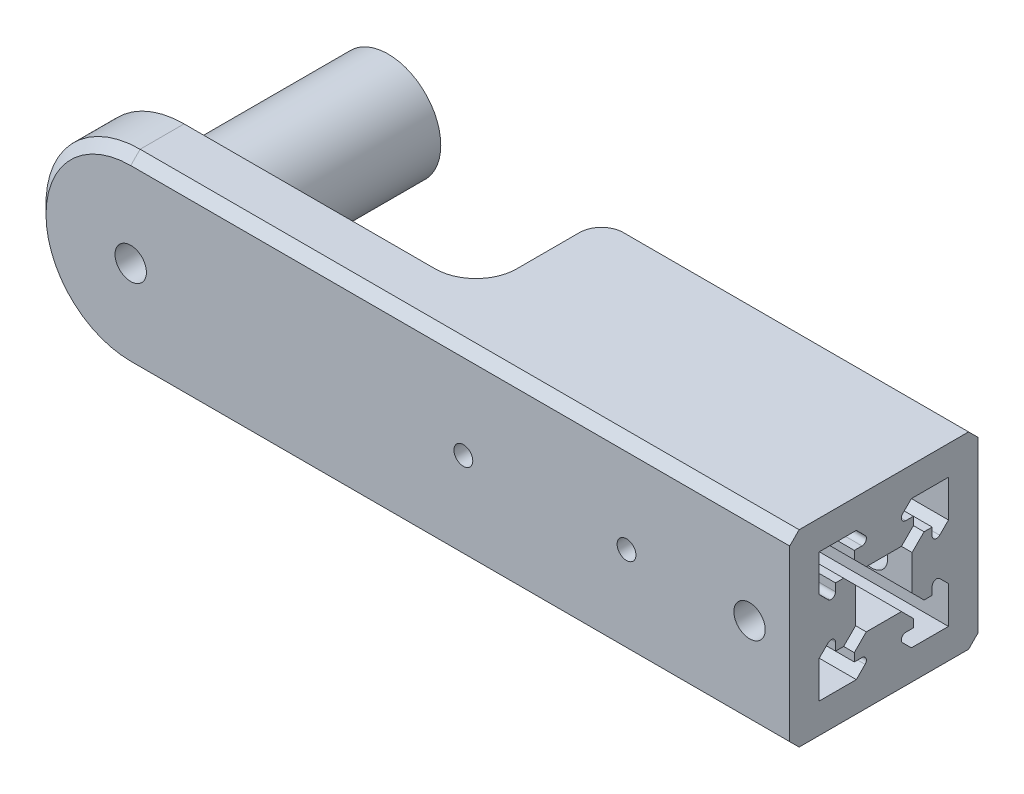
from build123d import *

# Parameters (mm, degrees)
SKETCH1_R           = 8.4
BOSS_EXTRUDE1_DEPTH = 30
SKETCH3_R           = 10
BOSS_EXTRUDE2_DEPTH = 1
BOSS_EXTRUDE3_DEPTH = 10
BOSS_EXTRUDE4_DEPTH = 30
CUT_EXTRUDE1_DEPTH  = 66
CHAMFER1_SIZE       = 1.5
SKETCH7_R           = 1.5
SKETCH7_R_2         = 2.5
CUT_EXTRUDE2_DEPTH  = 42


with BuildPart() as part:
    # Sketch1 → Boss-Extrude1 (new body)
    with BuildSketch(Plane.XY):
        Circle(SKETCH1_R)
    extrude(amount=BOSS_EXTRUDE1_DEPTH)

    # Sketch3 → Boss-Extrude2 (add)
    with BuildSketch(Plane.XY.offset(30)):
        Circle(SKETCH3_R)
    extrude(amount=BOSS_EXTRUDE2_DEPTH)

    # Sketch4 → Boss-Extrude3 (add)
    with BuildSketch(Plane.XY.offset(31)):
        with BuildLine():
            Line((0, 15), (105, 15))
            Line((105, 15), (105, -15))
            Line((105, -15), (0, -15))
            ThreePointArc((0, -15), (-15, 0), (0, 15))
        make_face()
    extrude(amount=BOSS_EXTRUDE3_DEPTH)

    # Sketch5 → Boss-Extrude4 (add)
    with BuildSketch(Plane(origin=(0, 15, 0), x_dir=(1, 0, 0), z_dir=(0, 1, 0))):
        with BuildLine():
            Line((40, -31), (105, -31))
            Line((105, -31), (105, -11))
            Line((105, -11), (50, -11))
            ThreePointArc((50, -11), (46.464466094, -12.464466094), (45, -16))
            Line((45, -16), (45, -26))
            ThreePointArc((45, -26), (43.535533906, -29.535533906), (40, -31))
        make_face()
    extrude(amount=-BOSS_EXTRUDE4_DEPTH)

    # Sketch6 → Cut-Extrude1 (cut)
    with BuildSketch(Plane(origin=(105, 0, 0), x_dir=(0, 0, -1), z_dir=(1, 0, 0))):
        with BuildLine():
            Line((-23.197056275, 4.553712276), (-28.802943725, 4.553712276))
            Line((-28.802943725, 4.553712276), (-30.710050506, 6.460819058))
            Line((-30.710050506, 6.460819058), (-30.710050506, 7.753712276))
            Line((-30.710050506, 7.753712276), (-29.482842712, 7.753712276))
            ThreePointArc((-29.482842712, 7.753712276), (-28.83612704, 8.185833874), (-28.987867966, 8.948687023))
            Line((-28.987867966, 8.948687023), (-30.387867966, 10.348687023))
            Line((-30.387867966, 10.348687023), (-36.294974747, 10.348687023))
            Line((-36.294974747, 10.348687023), (-36.294974747, 4.441580242))
            Line((-36.294974747, 4.441580242), (-34.894974747, 3.041580242))
            ThreePointArc((-34.894974747, 3.041580242), (-34.132121597, 2.889839316), (-33.7, 3.536554989))
            Line((-33.7, 3.536554989), (-33.7, 4.763762783))
            Line((-33.7, 4.763762783), (-32.407106781, 4.763762783))
            Line((-32.407106781, 4.763762783), (-30.5, 2.856656002))
            Line((-30.5, 2.856656002), (-30.5, -2.749231449))
            Line((-30.5, -2.749231449), (-32.407106781, -4.65633823))
            Line((-32.407106781, -4.65633823), (-33.7, -4.65633823))
            Line((-33.7, -4.65633823), (-33.7, -3.429130436))
            ThreePointArc((-33.7, -3.429130436), (-34.132121597, -2.782414763), (-34.894974747, -2.934155689))
            Line((-34.894974747, -2.934155689), (-36.294974747, -4.334155689))
            Line((-36.294974747, -4.334155689), (-36.294974747, -10.24126247))
            Line((-36.294974747, -10.24126247), (-30.387867966, -10.24126247))
            Line((-30.387867966, -10.24126247), (-28.987867966, -8.84126247))
            ThreePointArc((-28.987867966, -8.84126247), (-28.83612704, -8.078409321), (-29.482842712, -7.646287724))
            Line((-29.482842712, -7.646287724), (-30.710050506, -7.646287724))
            Line((-30.710050506, -7.646287724), (-30.710050506, -6.353394505))
            Line((-30.710050506, -6.353394505), (-28.802943725, -4.446287724))
            Line((-28.802943725, -4.446287724), (-23.197056275, -4.446287724))
            Line((-23.197056275, -4.446287724), (-21.289949494, -6.353394505))
            Line((-21.289949494, -6.353394505), (-21.289949494, -7.646287724))
            Line((-21.289949494, -7.646287724), (-22.517157288, -7.646287724))
            ThreePointArc((-22.517157288, -7.646287724), (-23.16387296, -8.078409321), (-23.012132034, -8.84126247))
            Line((-23.012132034, -8.84126247), (-21.612132034, -10.24126247))
            Line((-21.612132034, -10.24126247), (-15.705025253, -10.24126247))
            Line((-15.705025253, -10.24126247), (-15.705025253, -4.334155689))
            Line((-15.705025253, -4.334155689), (-17.105025253, -2.934155689))
            ThreePointArc((-17.105025253, -2.934155689), (-17.867878403, -2.782414763), (-18.3, -3.429130436))
            Line((-18.3, -3.429130436), (-18.3, -4.65633823))
            Line((-18.3, -4.65633823), (-19.592893219, -4.65633823))
            Line((-19.592893219, -4.65633823), (-21.5, -2.749231449))
            Line((-21.5, -2.749231449), (-21.5, 2.856656002))
            Line((-21.5, 2.856656002), (-19.592893219, 4.763762783))
            Line((-19.592893219, 4.763762783), (-18.3, 4.763762783))
            Line((-18.3, 4.763762783), (-18.3, 3.536554989))
            ThreePointArc((-18.3, 3.536554989), (-17.867878403, 2.889839316), (-17.105025253, 3.041580242))
            Line((-17.105025253, 3.041580242), (-15.705025253, 4.441580242))
            Line((-15.705025253, 4.441580242), (-15.705025253, 10.348687023))
            Line((-15.705025253, 10.348687023), (-21.612132034, 10.348687023))
            Line((-21.612132034, 10.348687023), (-23.012132034, 8.948687023))
            ThreePointArc((-23.012132034, 8.948687023), (-23.16387296, 8.185833874), (-22.517157288, 7.753712276))
            Line((-22.517157288, 7.753712276), (-21.289949494, 7.753712276))
            Line((-21.289949494, 7.753712276), (-21.289949494, 6.460819058))
            Line((-21.289949494, 6.460819058), (-23.197056275, 4.553712276))
        make_face()
    extrude(amount=-CUT_EXTRUDE1_DEPTH, mode=Mode.SUBTRACT)

    # Chamfer1
    chamfer1_edges = [part.edges().sort_by_distance(p)[0] for p in [
        (-15, 0, 31),
        (20, -15, 31),
        (-15, 0, 41),
        (52.5, -15, 41),
        (52.5, 15, 41),
        (20, 15, 31),
        (43.535533906, -15, 29.535533906),
        (45, -15, 21),
        (46.464466094, -15, 12.464466094),
        (77.5, -15, 11),
        (77.5, 15, 11),
        (46.464466094, 15, 12.464466094),
        (45, 15, 21),
        (43.535533906, 15, 29.535533906),
    ]]
    chamfer(chamfer1_edges, length=CHAMFER1_SIZE)

    # Sketch7 → Cut-Extrude2 (cut, through all)
    with BuildSketch(Plane.XY.offset(41)):
        with Locations((53, 0)):
            Circle(SKETCH7_R)
        with Locations((79, 0)):
            Circle(SKETCH7_R)
        with Locations((98.6, 0)):
            Circle(SKETCH7_R_2)
        Circle(SKETCH7_R_2)
    extrude(amount=-CUT_EXTRUDE2_DEPTH, mode=Mode.SUBTRACT)


solid = part.part
